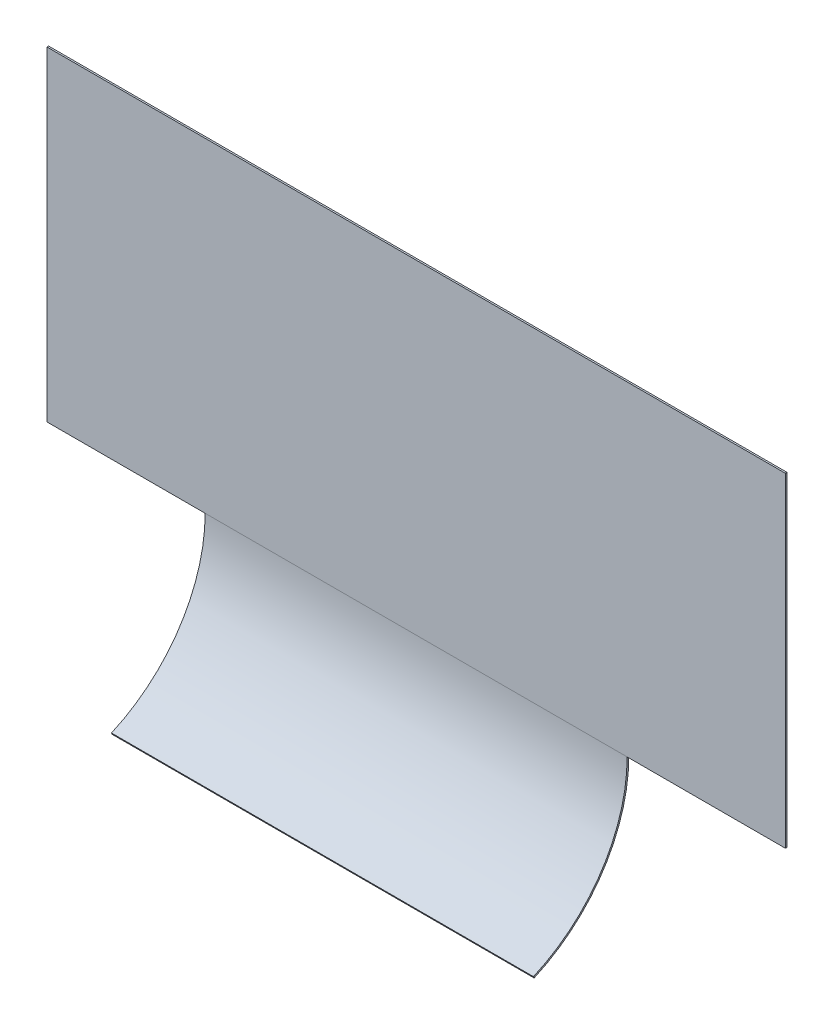
from build123d import *

# Parameters (mm, degrees)
EXTRUDE_THIN1_DEPTH = 203.2
SKETCH2_W           = 711.2
SKETCH2_H           = 312.7375
BOSS_EXTRUDE1_DEPTH = 1.5875


with BuildPart() as part:
    # Sketch1 → Extrude-Thin1 (new body, symmetric)
    with BuildSketch(Plane(origin=(0, 0, 0), x_dir=(0, 0, -1), z_dir=(1, 0, 0))):
        with BuildLine():
            ThreePointArc((60.57513929, -138.1125), (126.253511536, -82.489156748), (150.8125, 0))
            Line((150.8125, 0), (150.8125, 312.7375))
            Line((150.8125, 312.7375), (152.4127, 312.7375))
            Line((152.4127, 312.7375), (152.4127, 0))
            ThreePointArc((152.4127, 0), (127.593127743, -83.364410117), (61.217873399, -139.577946316))
            Line((61.217873399, -139.577946316), (60.57513929, -138.1125))
        make_face()
    extrude(amount=EXTRUDE_THIN1_DEPTH, both=True)

    # Sketch2 → Boss-Extrude1 (add)
    with BuildSketch(Plane.XY.offset(-150.8125)):
        with Locations((0, 156.36875)):
            Rectangle(SKETCH2_W, SKETCH2_H)
    extrude(amount=-BOSS_EXTRUDE1_DEPTH)


solid = part.part
